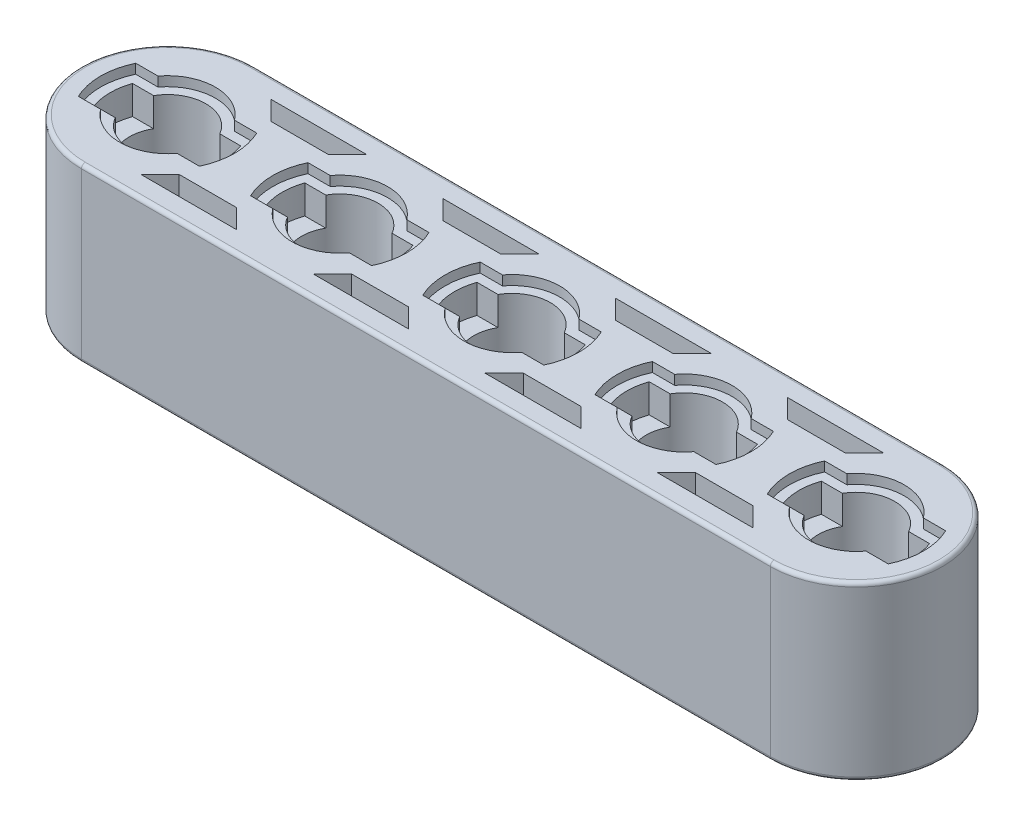
from build123d import *

# Parameters (mm, degrees)
BOSS_EXTRUDE1_DEPTH    = 4.5
SKETCH3_R              = 2
CUT_EXTRUDE1_DEPTH     = 5.5
CUT_EXTRUDE2_DEPTH     = 2
CUT_EXTRUDE3_DEPTH     = 0.5
CUT_EXTRUDE5_DEPTH     = 3
LPATTERN2_COUNT        = 4
LPATTERN2_PITCH        = 9
LPATTERN2_COPY_1_DEPTH = 3
LPATTERN2_COPY_2_DEPTH = 3
LPATTERN2_COPY_3_DEPTH = 3
LPATTERN3_COUNT        = 5
LPATTERN3_PITCH        = 9
LPATTERN3_COPY_1_DEPTH = 2
LPATTERN3_COPY_2_DEPTH = 2
LPATTERN3_COPY_3_DEPTH = 2
LPATTERN3_COPY_4_DEPTH = 2
LPATTERN3_COPY_5_DEPTH = 0.5
LPATTERN3_COPY_6_DEPTH = 0.5
LPATTERN3_COPY_7_DEPTH = 0.5
LPATTERN3_COPY_8_DEPTH = 0.5
FILLET1_R              = 0.2


with BuildPart() as part:
    # Sketch2 → Boss-Extrude1 (new body, symmetric)
    with BuildSketch(Plane(origin=(0, 0, 0), x_dir=(1, 0, 0), z_dir=(0, 1, 0))):
        with BuildLine():
            Line((-18, 4.5), (18, 4.5))
            ThreePointArc((18, 4.5), (22.5, 0), (18, -4.5))
            Line((18, -4.5), (-18, -4.5))
            ThreePointArc((-18, -4.5), (-22.5, 0), (-18, 4.5))
        make_face()
    extrude(amount=BOSS_EXTRUDE1_DEPTH, both=True)

    # Sketch3 → Cut-Extrude1 (cut, symmetric)
    with BuildSketch(Plane(origin=(0, 0, 0), x_dir=(1, 0, 0), z_dir=(0, 1, 0))):
        with Locations((-18, 0)):
            Circle(SKETCH3_R)
    cut_extrude1 = extrude(amount=CUT_EXTRUDE1_DEPTH, both=True, mode=Mode.SUBTRACT)

    # Sketch4 → Cut-Extrude2 (cut)
    with BuildSketch(Plane(origin=(0, 4.5, 0), x_dir=(1, 0, 0), z_dir=(0, 1, 0))):
        with BuildLine():
            ThreePointArc((-21, -1.5e-08), (-20.956795678, -0.507305943), (-20.828427125, -1))
            Line((-20.828427125, -1), (-19.732050808, -1))
            ThreePointArc((-19.732050808, -1), (-20, 0), (-19.732050808, 1))
            Line((-19.732050808, 1), (-20.828427125, 1))
            ThreePointArc((-20.828427125, 1), (-20.95679568, 0.507305929), (-21, -1.5e-08))
        make_face()
        with BuildLine():
            Line((-16.267949192, -1), (-15.171572875, -1))
            ThreePointArc((-15.171572875, -1), (-15.043204321, -0.507305936), (-15, 0))
            ThreePointArc((-15, 0), (-15.043204321, 0.507305936), (-15.171572875, 1))
            Line((-15.171572875, 1), (-16.267949192, 1))
            ThreePointArc((-16.267949192, 1), (-16.068148347, 0.51763809), (-16, 0))
            ThreePointArc((-16, 0), (-16.068148347, -0.51763809), (-16.267949192, -1))
        make_face()
        with BuildLine():
            ThreePointArc((-19.732050808, 1), (-20, 0), (-19.732050808, -1))
            Line((-19.732050808, -1), (-16.267949192, -1))
            ThreePointArc((-16.267949192, -1), (-16.068148347, -0.51763809), (-16, 0))
            ThreePointArc((-16, 0), (-16.068148347, 0.51763809), (-16.267949192, 1))
            Line((-16.267949192, 1), (-19.732050808, 1))
        make_face()
    cut_extrude2 = extrude(amount=-CUT_EXTRUDE2_DEPTH, mode=Mode.SUBTRACT)

    # Sketch5 → Cut-Extrude3 (cut)
    with BuildSketch(Plane(origin=(0, 4.5, 0), x_dir=(1, 0, 0), z_dir=(0, 1, 0))):
        with BuildLine():
            Line((-21.16227766, 1.5), (-20, 1.5))
            ThreePointArc((-20, 1.5), (-18, 2.5), (-16, 1.5))
            Line((-16, 1.5), (-14.83772234, 1.5))
            ThreePointArc((-14.83772234, 1.5), (-14.5, 0), (-14.83772234, -1.5))
            Line((-14.83772234, -1.5), (-16, -1.5))
            ThreePointArc((-16, -1.5), (-18, -2.5), (-20, -1.5))
            Line((-20, -1.5), (-21.16227766, -1.5))
            ThreePointArc((-21.16227766, -1.5), (-21.5, 0), (-21.16227766, 1.5))
        make_face()
        with BuildLine():
            Line((-16.267949192, -1), (-15.171572875, -1))
            ThreePointArc((-15.171572875, -1), (-15, 0), (-15.171572875, 1))
            Line((-15.171572875, 1), (-16.267949192, 1))
            ThreePointArc((-16.267949192, 1), (-18, 2), (-19.732050808, 1))
            Line((-19.732050808, 1), (-20.828427125, 1))
            ThreePointArc((-20.828427125, 1), (-21, 0), (-20.828427125, -1))
            Line((-20.828427125, -1), (-19.732050808, -1))
            ThreePointArc((-19.732050808, -1), (-18, -2), (-16.267949192, -1))
        make_face(mode=Mode.SUBTRACT)
    cut_extrude3 = extrude(amount=-CUT_EXTRUDE3_DEPTH, mode=Mode.SUBTRACT)

    # Sketch7 → Cut-Extrude5 (cut)
    with BuildSketch(Plane(origin=(0, 4.5, 0), x_dir=(1, 0, 0), z_dir=(0, 1, 0))):
        Polygon((-16, 3.4), (-11, 3.4), (-12, 2.4), (-15, 2.4), align=None)
        Polygon((-11, -3.4), (-12, -2.4), (-15, -2.4), (-16, -3.4), align=None)
    cut_extrude5 = extrude(amount=-CUT_EXTRUDE5_DEPTH, mode=Mode.SUBTRACT)

    # Mirror3: Cut-Extrude2, Cut-Extrude3 across plane
    add(cut_extrude2.mirror(Plane.ZX), mode=Mode.SUBTRACT)
    add(cut_extrude3.mirror(Plane.ZX), mode=Mode.SUBTRACT)

    # Mirror4: Cut-Extrude5 across plane
    add(cut_extrude5.mirror(Plane.ZX), mode=Mode.SUBTRACT)

    # LPattern2: Cut-Extrude5 ×4
    with Locations(*[(i * LPATTERN2_PITCH, 0, 0) for i in range(1, LPATTERN2_COUNT)]):
        add(cut_extrude5, mode=Mode.SUBTRACT)

    # LPattern2 copy 1 sketch → LPattern2 copy 1 (cut)
    with BuildSketch(Plane(origin=(9, -4.5, 0), x_dir=(1, 0, 0), z_dir=(0, -1, 0))):
        Polygon((-16, -3.4), (-11, -3.4), (-12, -2.4), (-15, -2.4), align=None)
        Polygon((-11, 3.4), (-12, 2.4), (-15, 2.4), (-16, 3.4), align=None)
    extrude(amount=-LPATTERN2_COPY_1_DEPTH, mode=Mode.SUBTRACT)

    # LPattern2 copy 2 sketch → LPattern2 copy 2 (cut)
    with BuildSketch(Plane(origin=(18, -4.5, 0), x_dir=(1, 0, 0), z_dir=(0, -1, 0))):
        Polygon((-16, -3.4), (-11, -3.4), (-12, -2.4), (-15, -2.4), align=None)
        Polygon((-11, 3.4), (-12, 2.4), (-15, 2.4), (-16, 3.4), align=None)
    extrude(amount=-LPATTERN2_COPY_2_DEPTH, mode=Mode.SUBTRACT)

    # LPattern2 copy 3 sketch → LPattern2 copy 3 (cut)
    with BuildSketch(Plane(origin=(27, -4.5, 0), x_dir=(1, 0, 0), z_dir=(0, -1, 0))):
        Polygon((-16, -3.4), (-11, -3.4), (-12, -2.4), (-15, -2.4), align=None)
        Polygon((-11, 3.4), (-12, 2.4), (-15, 2.4), (-16, 3.4), align=None)
    extrude(amount=-LPATTERN2_COPY_3_DEPTH, mode=Mode.SUBTRACT)

    # LPattern3: Cut-Extrude1, Cut-Extrude2, Cut-Extrude3 ×5
    with Locations(*[(i * LPATTERN3_PITCH, 0, 0) for i in range(1, LPATTERN3_COUNT)]):
        add(cut_extrude1, mode=Mode.SUBTRACT)
        add(cut_extrude2, mode=Mode.SUBTRACT)
        add(cut_extrude3, mode=Mode.SUBTRACT)

    # LPattern3 copy 1 sketch → LPattern3 copy 1 (cut)
    with BuildSketch(Plane(origin=(9, -4.5, 0), x_dir=(1, 0, 0), z_dir=(0, -1, 0))):
        with BuildLine():
            ThreePointArc((-21, 1.5e-08), (-20.956795678, 0.507305943), (-20.828427125, 1))
            Line((-20.828427125, 1), (-19.732050808, 1))
            ThreePointArc((-19.732050808, 1), (-20, 0), (-19.732050808, -1))
            Line((-19.732050808, -1), (-20.828427125, -1))
            ThreePointArc((-20.828427125, -1), (-20.95679568, -0.507305929), (-21, 1.5e-08))
        make_face()
        with BuildLine():
            Line((-16.267949192, 1), (-15.171572875, 1))
            ThreePointArc((-15.171572875, 1), (-15.043204321, 0.507305936), (-15, 0))
            ThreePointArc((-15, 0), (-15.043204321, -0.507305936), (-15.171572875, -1))
            Line((-15.171572875, -1), (-16.267949192, -1))
            ThreePointArc((-16.267949192, -1), (-16.068148347, -0.51763809), (-16, 0))
            ThreePointArc((-16, 0), (-16.068148347, 0.51763809), (-16.267949192, 1))
        make_face()
        with BuildLine():
            ThreePointArc((-19.732050808, -1), (-20, 0), (-19.732050808, 1))
            Line((-19.732050808, 1), (-16.267949192, 1))
            ThreePointArc((-16.267949192, 1), (-16.068148347, 0.51763809), (-16, 0))
            ThreePointArc((-16, 0), (-16.068148347, -0.51763809), (-16.267949192, -1))
            Line((-16.267949192, -1), (-19.732050808, -1))
        make_face()
    extrude(amount=-LPATTERN3_COPY_1_DEPTH, mode=Mode.SUBTRACT)

    # LPattern3 copy 2 sketch → LPattern3 copy 2 (cut)
    with BuildSketch(Plane(origin=(18, -4.5, 0), x_dir=(1, 0, 0), z_dir=(0, -1, 0))):
        with BuildLine():
            ThreePointArc((-21, 1.5e-08), (-20.956795678, 0.507305943), (-20.828427125, 1))
            Line((-20.828427125, 1), (-19.732050808, 1))
            ThreePointArc((-19.732050808, 1), (-20, 0), (-19.732050808, -1))
            Line((-19.732050808, -1), (-20.828427125, -1))
            ThreePointArc((-20.828427125, -1), (-20.95679568, -0.507305929), (-21, 1.5e-08))
        make_face()
        with BuildLine():
            Line((-16.267949192, 1), (-15.171572875, 1))
            ThreePointArc((-15.171572875, 1), (-15.043204321, 0.507305936), (-15, 0))
            ThreePointArc((-15, 0), (-15.043204321, -0.507305936), (-15.171572875, -1))
            Line((-15.171572875, -1), (-16.267949192, -1))
            ThreePointArc((-16.267949192, -1), (-16.068148347, -0.51763809), (-16, 0))
            ThreePointArc((-16, 0), (-16.068148347, 0.51763809), (-16.267949192, 1))
        make_face()
        with BuildLine():
            ThreePointArc((-19.732050808, -1), (-20, 0), (-19.732050808, 1))
            Line((-19.732050808, 1), (-16.267949192, 1))
            ThreePointArc((-16.267949192, 1), (-16.068148347, 0.51763809), (-16, 0))
            ThreePointArc((-16, 0), (-16.068148347, -0.51763809), (-16.267949192, -1))
            Line((-16.267949192, -1), (-19.732050808, -1))
        make_face()
    extrude(amount=-LPATTERN3_COPY_2_DEPTH, mode=Mode.SUBTRACT)

    # LPattern3 copy 3 sketch → LPattern3 copy 3 (cut)
    with BuildSketch(Plane(origin=(27, -4.5, 0), x_dir=(1, 0, 0), z_dir=(0, -1, 0))):
        with BuildLine():
            ThreePointArc((-21, 1.5e-08), (-20.956795678, 0.507305943), (-20.828427125, 1))
            Line((-20.828427125, 1), (-19.732050808, 1))
            ThreePointArc((-19.732050808, 1), (-20, 0), (-19.732050808, -1))
            Line((-19.732050808, -1), (-20.828427125, -1))
            ThreePointArc((-20.828427125, -1), (-20.95679568, -0.507305929), (-21, 1.5e-08))
        make_face()
        with BuildLine():
            Line((-16.267949192, 1), (-15.171572875, 1))
            ThreePointArc((-15.171572875, 1), (-15.043204321, 0.507305936), (-15, 0))
            ThreePointArc((-15, 0), (-15.043204321, -0.507305936), (-15.171572875, -1))
            Line((-15.171572875, -1), (-16.267949192, -1))
            ThreePointArc((-16.267949192, -1), (-16.068148347, -0.51763809), (-16, 0))
            ThreePointArc((-16, 0), (-16.068148347, 0.51763809), (-16.267949192, 1))
        make_face()
        with BuildLine():
            ThreePointArc((-19.732050808, -1), (-20, 0), (-19.732050808, 1))
            Line((-19.732050808, 1), (-16.267949192, 1))
            ThreePointArc((-16.267949192, 1), (-16.068148347, 0.51763809), (-16, 0))
            ThreePointArc((-16, 0), (-16.068148347, -0.51763809), (-16.267949192, -1))
            Line((-16.267949192, -1), (-19.732050808, -1))
        make_face()
    extrude(amount=-LPATTERN3_COPY_3_DEPTH, mode=Mode.SUBTRACT)

    # LPattern3 copy 4 sketch → LPattern3 copy 4 (cut)
    with BuildSketch(Plane(origin=(36, -4.5, 0), x_dir=(1, 0, 0), z_dir=(0, -1, 0))):
        with BuildLine():
            ThreePointArc((-21, 1.5e-08), (-20.956795678, 0.507305943), (-20.828427125, 1))
            Line((-20.828427125, 1), (-19.732050808, 1))
            ThreePointArc((-19.732050808, 1), (-20, 0), (-19.732050808, -1))
            Line((-19.732050808, -1), (-20.828427125, -1))
            ThreePointArc((-20.828427125, -1), (-20.95679568, -0.507305929), (-21, 1.5e-08))
        make_face()
        with BuildLine():
            Line((-16.267949192, 1), (-15.171572875, 1))
            ThreePointArc((-15.171572875, 1), (-15.043204321, 0.507305936), (-15, 0))
            ThreePointArc((-15, 0), (-15.043204321, -0.507305936), (-15.171572875, -1))
            Line((-15.171572875, -1), (-16.267949192, -1))
            ThreePointArc((-16.267949192, -1), (-16.068148347, -0.51763809), (-16, 0))
            ThreePointArc((-16, 0), (-16.068148347, 0.51763809), (-16.267949192, 1))
        make_face()
        with BuildLine():
            ThreePointArc((-19.732050808, -1), (-20, 0), (-19.732050808, 1))
            Line((-19.732050808, 1), (-16.267949192, 1))
            ThreePointArc((-16.267949192, 1), (-16.068148347, 0.51763809), (-16, 0))
            ThreePointArc((-16, 0), (-16.068148347, -0.51763809), (-16.267949192, -1))
            Line((-16.267949192, -1), (-19.732050808, -1))
        make_face()
    extrude(amount=-LPATTERN3_COPY_4_DEPTH, mode=Mode.SUBTRACT)

    # LPattern3 copy 5 sketch → LPattern3 copy 5 (cut)
    with BuildSketch(Plane(origin=(9, -4.5, 0), x_dir=(1, 0, 0), z_dir=(0, -1, 0))):
        with BuildLine():
            Line((-21.16227766, -1.5), (-20, -1.5))
            ThreePointArc((-20, -1.5), (-18, -2.5), (-16, -1.5))
            Line((-16, -1.5), (-14.83772234, -1.5))
            ThreePointArc((-14.83772234, -1.5), (-14.5, 0), (-14.83772234, 1.5))
            Line((-14.83772234, 1.5), (-16, 1.5))
            ThreePointArc((-16, 1.5), (-18, 2.5), (-20, 1.5))
            Line((-20, 1.5), (-21.16227766, 1.5))
            ThreePointArc((-21.16227766, 1.5), (-21.5, 0), (-21.16227766, -1.5))
        make_face()
        with BuildLine():
            Line((-16.267949192, 1), (-15.171572875, 1))
            ThreePointArc((-15.171572875, 1), (-15, 0), (-15.171572875, -1))
            Line((-15.171572875, -1), (-16.267949192, -1))
            ThreePointArc((-16.267949192, -1), (-18, -2), (-19.732050808, -1))
            Line((-19.732050808, -1), (-20.828427125, -1))
            ThreePointArc((-20.828427125, -1), (-21, 0), (-20.828427125, 1))
            Line((-20.828427125, 1), (-19.732050808, 1))
            ThreePointArc((-19.732050808, 1), (-18, 2), (-16.267949192, 1))
        make_face(mode=Mode.SUBTRACT)
    extrude(amount=-LPATTERN3_COPY_5_DEPTH, mode=Mode.SUBTRACT)

    # LPattern3 copy 6 sketch → LPattern3 copy 6 (cut)
    with BuildSketch(Plane(origin=(18, -4.5, 0), x_dir=(1, 0, 0), z_dir=(0, -1, 0))):
        with BuildLine():
            Line((-21.16227766, -1.5), (-20, -1.5))
            ThreePointArc((-20, -1.5), (-18, -2.5), (-16, -1.5))
            Line((-16, -1.5), (-14.83772234, -1.5))
            ThreePointArc((-14.83772234, -1.5), (-14.5, 0), (-14.83772234, 1.5))
            Line((-14.83772234, 1.5), (-16, 1.5))
            ThreePointArc((-16, 1.5), (-18, 2.5), (-20, 1.5))
            Line((-20, 1.5), (-21.16227766, 1.5))
            ThreePointArc((-21.16227766, 1.5), (-21.5, 0), (-21.16227766, -1.5))
        make_face()
        with BuildLine():
            Line((-16.267949192, 1), (-15.171572875, 1))
            ThreePointArc((-15.171572875, 1), (-15, 0), (-15.171572875, -1))
            Line((-15.171572875, -1), (-16.267949192, -1))
            ThreePointArc((-16.267949192, -1), (-18, -2), (-19.732050808, -1))
            Line((-19.732050808, -1), (-20.828427125, -1))
            ThreePointArc((-20.828427125, -1), (-21, 0), (-20.828427125, 1))
            Line((-20.828427125, 1), (-19.732050808, 1))
            ThreePointArc((-19.732050808, 1), (-18, 2), (-16.267949192, 1))
        make_face(mode=Mode.SUBTRACT)
    extrude(amount=-LPATTERN3_COPY_6_DEPTH, mode=Mode.SUBTRACT)

    # LPattern3 copy 7 sketch → LPattern3 copy 7 (cut)
    with BuildSketch(Plane(origin=(27, -4.5, 0), x_dir=(1, 0, 0), z_dir=(0, -1, 0))):
        with BuildLine():
            Line((-21.16227766, -1.5), (-20, -1.5))
            ThreePointArc((-20, -1.5), (-18, -2.5), (-16, -1.5))
            Line((-16, -1.5), (-14.83772234, -1.5))
            ThreePointArc((-14.83772234, -1.5), (-14.5, 0), (-14.83772234, 1.5))
            Line((-14.83772234, 1.5), (-16, 1.5))
            ThreePointArc((-16, 1.5), (-18, 2.5), (-20, 1.5))
            Line((-20, 1.5), (-21.16227766, 1.5))
            ThreePointArc((-21.16227766, 1.5), (-21.5, 0), (-21.16227766, -1.5))
        make_face()
        with BuildLine():
            Line((-16.267949192, 1), (-15.171572875, 1))
            ThreePointArc((-15.171572875, 1), (-15, 0), (-15.171572875, -1))
            Line((-15.171572875, -1), (-16.267949192, -1))
            ThreePointArc((-16.267949192, -1), (-18, -2), (-19.732050808, -1))
            Line((-19.732050808, -1), (-20.828427125, -1))
            ThreePointArc((-20.828427125, -1), (-21, 0), (-20.828427125, 1))
            Line((-20.828427125, 1), (-19.732050808, 1))
            ThreePointArc((-19.732050808, 1), (-18, 2), (-16.267949192, 1))
        make_face(mode=Mode.SUBTRACT)
    extrude(amount=-LPATTERN3_COPY_7_DEPTH, mode=Mode.SUBTRACT)

    # LPattern3 copy 8 sketch → LPattern3 copy 8 (cut)
    with BuildSketch(Plane(origin=(36, -4.5, 0), x_dir=(1, 0, 0), z_dir=(0, -1, 0))):
        with BuildLine():
            Line((-21.16227766, -1.5), (-20, -1.5))
            ThreePointArc((-20, -1.5), (-18, -2.5), (-16, -1.5))
            Line((-16, -1.5), (-14.83772234, -1.5))
            ThreePointArc((-14.83772234, -1.5), (-14.5, 0), (-14.83772234, 1.5))
            Line((-14.83772234, 1.5), (-16, 1.5))
            ThreePointArc((-16, 1.5), (-18, 2.5), (-20, 1.5))
            Line((-20, 1.5), (-21.16227766, 1.5))
            ThreePointArc((-21.16227766, 1.5), (-21.5, 0), (-21.16227766, -1.5))
        make_face()
        with BuildLine():
            Line((-16.267949192, 1), (-15.171572875, 1))
            ThreePointArc((-15.171572875, 1), (-15, 0), (-15.171572875, -1))
            Line((-15.171572875, -1), (-16.267949192, -1))
            ThreePointArc((-16.267949192, -1), (-18, -2), (-19.732050808, -1))
            Line((-19.732050808, -1), (-20.828427125, -1))
            ThreePointArc((-20.828427125, -1), (-21, 0), (-20.828427125, 1))
            Line((-20.828427125, 1), (-19.732050808, 1))
            ThreePointArc((-19.732050808, 1), (-18, 2), (-16.267949192, 1))
        make_face(mode=Mode.SUBTRACT)
    extrude(amount=-LPATTERN3_COPY_8_DEPTH, mode=Mode.SUBTRACT)

    # Fillet1
    fillet1_edges = [part.edges().sort_by_distance(p)[0] for p in [
        (22.5, 4.5, 0),
        (0, 4.5, -4.5),
        (-22.5, 4.5, 0),
        (0, -4.5, -4.5),
        (22.5, -4.5, 0),
        (0, -4.5, 4.5),
        (-22.5, -4.5, 0),
        (0, 4.5, 4.5),
    ]]
    fillet(fillet1_edges, radius=FILLET1_R)


solid = part.part
